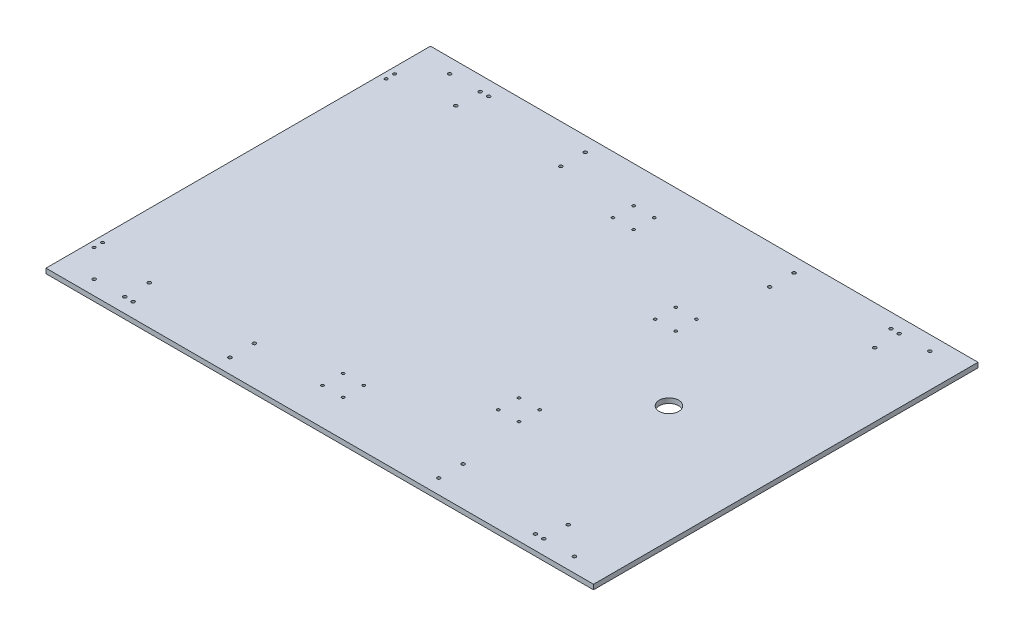
from build123d import *

# Parameters (mm, degrees)
SKETCH1_W                 = 714.375
SKETCH1_H                 = 501.65
BOSS_EXTRUDE1_DEPTH       = 6.35
SKETCH2_R                 = 2.15265
CUT_EXTRUDE1_DEPTH        = 7.35
BOSS_EXTRUDE2_START       = -467.29015
SKETCH4_W                 = 714.375
SKETCH4_H                 = 6.35
BOSS_EXTRUDE2_DEPTH       = 432.9303
F_8_CLEARANCE_HOLE1_D     = 4.3053
F_8_CLEARANCE_HOLE1_DEPTH = 74.422
F_8_CLEARANCE_HOLE1_TIP   = 1.293442612
F_8_CLEARANCE_HOLE2_D     = 4.3053
F_8_CLEARANCE_HOLE2_DEPTH = 74.422
F_8_CLEARANCE_HOLE2_TIP   = 1.293442612
SKETCH11_R                = 12.7
CUT_EXTRUDE4_DEPTH        = 83.82
F_6_CLEARANCE_HOLE1_D     = 3.7973
F_6_CLEARANCE_HOLE1_DEPTH = 74.422
F_6_CLEARANCE_HOLE1_TIP   = 1.140824014
SKETCH14_R                = 1.778
SKETCH14_R_2              = 1.779075966
CUT_EXTRUDE5_DEPTH        = 7.62
SKETCH15_R                = 2.15265
CUT_EXTRUDE6_DEPTH        = 6.35


with BuildPart() as part:
    # Sketch1 → Boss-Extrude1 (new body)
    with BuildSketch(Plane(origin=(0, 0, 0), x_dir=(1, 0, 0), z_dir=(0, 1, 0))):
        Rectangle(SKETCH1_W, SKETCH1_H)
    extrude(amount=BOSS_EXTRUDE1_DEPTH)

    # Sketch2 → Cut-Extrude1 (cut, through all)
    with BuildSketch(Plane(origin=(0, 6.35, 0), x_dir=(1, 0, 0), z_dir=(0, 1, 0))):
        with Locations((-114.3, -214.3125)):
            Circle(SKETCH2_R)
        with Locations((-228.6, -214.3125)):
            Circle(SKETCH2_R)
        with Locations((228.6, -214.3125)):
            Circle(SKETCH2_R)
        with Locations((114.3, -214.3125)):
            Circle(SKETCH2_R)
        with Locations((114.3, 214.3125)):
            Circle(SKETCH2_R)
        with Locations((228.6, 214.3125)):
            Circle(SKETCH2_R)
        with Locations((-228.6, 214.3125)):
            Circle(SKETCH2_R)
        with Locations((-114.3, 214.3125)):
            Circle(SKETCH2_R)
    extrude(amount=-CUT_EXTRUDE1_DEPTH, mode=Mode.SUBTRACT)

    # Sketch4 → Boss-Extrude2 (add)
    with BuildSketch(Plane.XY.offset(250.825).offset(BOSS_EXTRUDE2_START)):
        with Locations((0, 3.175)):
            Rectangle(SKETCH4_W, SKETCH4_H)
    extrude(amount=BOSS_EXTRUDE2_DEPTH)

    # #8 Clearance Hole1
    with Locations(Plane(origin=(0, 6.35, 0), x_dir=(1, 0, 0), z_dir=(0, 1, 0))):
        with Locations((-273.3675, 231.775), (-136.2075, 231.775), (136.2075, 231.775), (273.3675, 231.775), (273.3675, 200.025), (136.2075, 200.025), (-136.2075, 200.025), (-273.3675, 200.025), (-273.3675, -200.025), (-273.3675, -231.775), (-136.2075, -231.775), (-136.2075, -200.025), (136.2075, -200.025), (136.2075, -231.775), (273.3675, -231.775), (273.3675, -200.025)):
            Hole(F_8_CLEARANCE_HOLE1_D / 2, depth=F_8_CLEARANCE_HOLE1_DEPTH)
            with Locations((0, 0, -(F_8_CLEARANCE_HOLE1_DEPTH + F_8_CLEARANCE_HOLE1_TIP / 2))):  # 118° drill point
                Cone(0, F_8_CLEARANCE_HOLE1_D / 2, F_8_CLEARANCE_HOLE1_TIP, mode=Mode.SUBTRACT)

    # #8 Clearance Hole2
    with Locations(Plane(origin=(0, 6.35, 0), x_dir=(1, 0, 0), z_dir=(0, 1, 0))):
        with Locations((-313.309, 231.93248), (313.309, 231.93248), (313.309, -231.93248), (-313.309, -231.93248)):
            Hole(F_8_CLEARANCE_HOLE2_D / 2, depth=F_8_CLEARANCE_HOLE2_DEPTH)
            with Locations((0, 0, -(F_8_CLEARANCE_HOLE2_DEPTH + F_8_CLEARANCE_HOLE2_TIP / 2))):  # 118° drill point
                Cone(0, F_8_CLEARANCE_HOLE2_D / 2, F_8_CLEARANCE_HOLE2_TIP, mode=Mode.SUBTRACT)

    # Sketch11 → Cut-Extrude4 (cut)
    with BuildSketch(Plane(origin=(0, 6.35, 0), x_dir=(1, 0, 0), z_dir=(0, 1, 0))):
        with Locations((204.7875, 0)):
            Circle(SKETCH11_R)
    extrude(amount=-CUT_EXTRUDE4_DEPTH, mode=Mode.SUBTRACT)

    # #6 Clearance Hole1
    with Locations(Plane(origin=(0, 6.35, 0), x_dir=(1, 0, 0), z_dir=(0, 1, 0))):
        with Locations((-349.1357, 196.07911), (-349.1357, 184.92089), (-349.1357, -184.92089), (-349.1357, -196.07911)):
            Hole(F_6_CLEARANCE_HOLE1_D / 2, depth=F_6_CLEARANCE_HOLE1_DEPTH)
            with Locations((0, 0, -(F_6_CLEARANCE_HOLE1_DEPTH + F_6_CLEARANCE_HOLE1_TIP / 2))):  # 118° drill point
                Cone(0, F_6_CLEARANCE_HOLE1_D / 2, F_6_CLEARANCE_HOLE1_TIP, mode=Mode.SUBTRACT)

    # Sketch14 → Cut-Extrude5 (cut)
    with BuildSketch(Plane.XZ):
        with Locations((-44.331384182, 202.954384182)):
            Circle(SKETCH14_R)
        with Locations((-17.390615818, 202.954384182)):
            Circle(SKETCH14_R)
        with Locations((-17.390615818, 176.013615818)):
            Circle(SKETCH14_R)
        with Locations((-44.331384182, 176.013615818)):
            Circle(SKETCH14_R)
        with Locations((124.912884182, 115.768884182)):
            Circle(SKETCH14_R)
        with Locations((124.91212, 88.82888)):
            Circle(SKETCH14_R_2)
        with Locations((97.972115818, 88.828115818)):
            Circle(SKETCH14_R)
        with Locations((97.972115818, 115.768884182)):
            Circle(SKETCH14_R)
        with Locations((97.972115818, -88.828115818)):
            Circle(SKETCH14_R)
        with Locations((124.912884182, -88.828115818)):
            Circle(SKETCH14_R)
        with Locations((124.912884182, -115.768884182)):
            Circle(SKETCH14_R)
        with Locations((97.972115818, -115.768884182)):
            Circle(SKETCH14_R)
        with Locations((-44.331384182, -176.013615818)):
            Circle(SKETCH14_R)
        with Locations((-17.390615818, -176.013615818)):
            Circle(SKETCH14_R)
        with Locations((-17.390615818, -202.954384182)):
            Circle(SKETCH14_R)
        with Locations((-44.331384182, -202.954384182)):
            Circle(SKETCH14_R)
    extrude(amount=-CUT_EXTRUDE5_DEPTH, mode=Mode.SUBTRACT)

    # Sketch15 → Cut-Extrude6 (cut)
    with BuildSketch(Plane(origin=(0, 6.35, 0), x_dir=(1, 0, 0), z_dir=(0, 1, 0))):
        with Locations((-262.509, 231.93375)):
            Circle(SKETCH15_R)
        with Locations((262.509, 231.93375)):
            Circle(SKETCH15_R)
        with Locations((262.509, -231.93375)):
            Circle(SKETCH15_R)
        with Locations((-262.509, -231.93375)):
            Circle(SKETCH15_R)
    extrude(amount=-CUT_EXTRUDE6_DEPTH, mode=Mode.SUBTRACT)


solid = part.part
